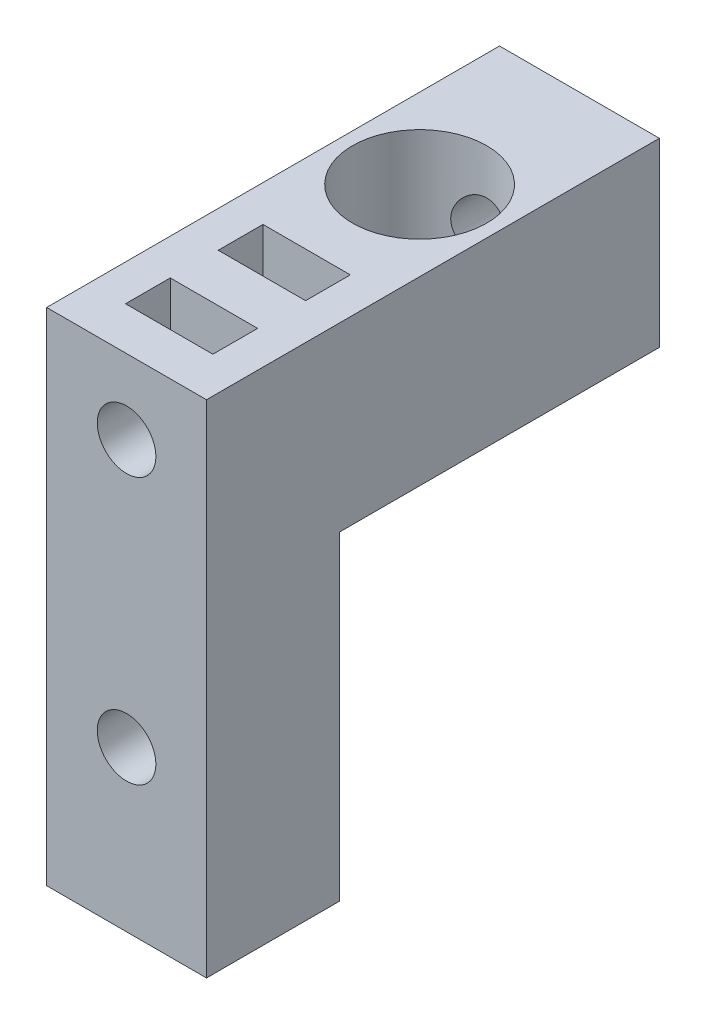
from build123d import *

# Parameters (mm, degrees)
SKETCH1_W                                       = 15
SKETCH1_H                                       = 47
BOSS_EXTRUDE1_DEPTH                             = 42.5
SKETCH2_W                                       = 30
SKETCH2_H                                       = 30
CUT_EXTRUDE1_DEPTH                              = 16
SKETCH3_R                                       = 2.75
CUT_EXTRUDE2_DEPTH                              = 15
CUT_EXTRUDE3_REACH                              = 49
SKETCH4_R                                       = 3.25
SKETCH5_R                                       = 2.75
CUT_EXTRUDE4_DEPTH                              = 28.5
CUT_EXTRUDE6_START                              = -7.2
SKETCH6_R                                       = 6.3
CUT_EXTRUDE6_DEPTH                              = 15
CSK_FOR_M6_FLAT_HEAD_MACHINE_SCREW1_D           = 6.6
CSK_FOR_M6_FLAT_HEAD_MACHINE_SCREW1_CSINK_D     = 12.6
CSK_FOR_M6_FLAT_HEAD_MACHINE_SCREW1_CSINK_ANGLE = 90
SKETCH10_W                                      = 8.2
SKETCH10_H                                      = 4.2
CUT_EXTRUDE7_DEPTH                              = 12


with BuildPart() as part:
    # Sketch1 → Boss-Extrude1 (new body)
    with BuildSketch(Plane.XY):
        with Locations((7.5, 23.5)):
            Rectangle(SKETCH1_W, SKETCH1_H)
    extrude(amount=BOSS_EXTRUDE1_DEPTH)

    # Sketch2 → Cut-Extrude1 (cut, through all)
    with BuildSketch(Plane.ZY):
        with Locations((15, 15)):
            Rectangle(SKETCH2_W, SKETCH2_H)
    extrude(amount=-CUT_EXTRUDE1_DEPTH, mode=Mode.SUBTRACT)

    # Sketch3 → Cut-Extrude2 (cut)
    with BuildSketch(Plane.XY.offset(42.5)):
        with Locations((7.5, 15)):
            Circle(SKETCH3_R)
        with Locations((7.5, 40)):
            Circle(SKETCH3_R)
    extrude(amount=-CUT_EXTRUDE2_DEPTH, mode=Mode.SUBTRACT)

    # Sketch4 → Cut-Extrude3 (cut, up to next)
    with BuildSketch(Plane(origin=(0, 47, 0), x_dir=(1, 0, 0), z_dir=(0, 1, 0)), mode=Mode.PRIVATE) as cut_extrude3_sk1:
        with Locations((7.5, -15)):
            Circle(SKETCH4_R)
    cut_extrude3_tool1 = extrude(cut_extrude3_sk1.sketch, amount=-CUT_EXTRUDE3_REACH, mode=Mode.PRIVATE) & part.part
    add(cut_extrude3_tool1.solids().sort_by_distance((7.5, 47, 15))[0], mode=Mode.SUBTRACT)

    # Sketch5 → Cut-Extrude4 (cut, through all)
    with BuildSketch(Plane.XY.offset(27.5)):
        with Locations((7.5, 40)):
            Circle(SKETCH5_R)
    extrude(amount=-CUT_EXTRUDE4_DEPTH, mode=Mode.SUBTRACT)

    # Sketch6 → Cut-Extrude6 (cut)
    with BuildSketch(Plane.XZ.offset(-30).offset(CUT_EXTRUDE6_START)):
        with Locations((7.5, 15)):
            Circle(SKETCH6_R)
    extrude(amount=-CUT_EXTRUDE6_DEPTH, mode=Mode.SUBTRACT)

    # CSK for M6 Flat Head Machine Screw1 (through all)
    with Locations(Plane(origin=(0, 37.2, 0), x_dir=(1, 0, 0), z_dir=(0, 1, 0))):
        with Locations((7.5, -15)):
            CounterSinkHole(CSK_FOR_M6_FLAT_HEAD_MACHINE_SCREW1_D / 2, CSK_FOR_M6_FLAT_HEAD_MACHINE_SCREW1_CSINK_D / 2, counter_sink_angle=CSK_FOR_M6_FLAT_HEAD_MACHINE_SCREW1_CSINK_ANGLE)

    # Sketch10 → Cut-Extrude7 (cut)
    with BuildSketch(Plane(origin=(0, 47, 0), x_dir=(1, 0, 0), z_dir=(0, 1, 0))):
        with Locations((7.5, -36.4)):
            Rectangle(SKETCH10_W, SKETCH10_H)
        with Locations((7.5, -27.7)):
            Rectangle(SKETCH10_W, SKETCH10_H)
    extrude(amount=-CUT_EXTRUDE7_DEPTH, mode=Mode.SUBTRACT)


solid = part.part
